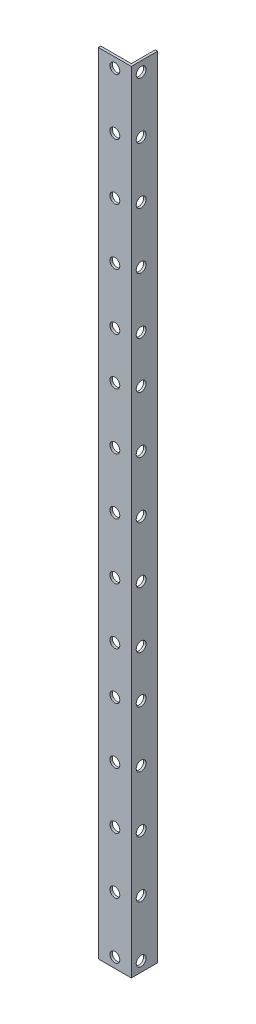
from build123d import *

# Parameters (mm, degrees)
BOSS_EXTRUDE1_DEPTH       = 360
CUT_EXTRUDE1_REACH        = 3.1
SKETCH2_R                 = 2.25
SKETCH3_R                 = 2.25
CUT_EXTRUDE2_DEPTH        = 1.1
LPATTERN1_COUNT           = 5
LPATTERN1_PITCH           = 25.65625
LPATTERN2_COUNT           = 3
LPATTERN2_PITCH           = 124.1875
LPATTERN2_COPY_1_SKETCH_R = 2.25
LPATTERN2_COPY_1_DEPTH    = 1.1
LPATTERN2_COPY_2_SKETCH_R = 2.25
LPATTERN2_COPY_2_DEPTH    = 1.1
LPATTERN2_COPY_3_SKETCH_R = 2.25
LPATTERN2_COPY_3_DEPTH    = 1.1
LPATTERN2_COPY_4_SKETCH_R = 2.25
LPATTERN2_COPY_4_DEPTH    = 1.1
LPATTERN2_COPY_5_SKETCH_R = 2.25
LPATTERN2_COPY_5_DEPTH    = 1.1
LPATTERN2_COPY_6_SKETCH_R = 2.25
LPATTERN2_COPY_6_DEPTH    = 1.1
LPATTERN2_COPY_7_SKETCH_R = 2.25
LPATTERN2_COPY_7_DEPTH    = 1.1
LPATTERN2_COPY_8_SKETCH_R = 2.25
LPATTERN2_COPY_8_DEPTH    = 1.1


with BuildPart() as part:
    # Sketch1 → Boss-Extrude1 (new body)
    with BuildSketch(Plane(origin=(0, 0, 0), x_dir=(1, 0, 0), z_dir=(0, 1, 0))):
        Polygon((0, 0), (15, 0), (15, 12), (13.9, 12), (13.9, 1.1), (0, 1.1), align=None)
    extrude(amount=BOSS_EXTRUDE1_DEPTH)

    # Sketch2 → Cut-Extrude1 (cut, up to next)
    with BuildSketch(Plane.ZY.offset(-13.9), mode=Mode.PRIVATE) as cut_extrude1_sk1:
        with Locations((-4.5, 329.8125)):
            Circle(SKETCH2_R)
    cut_extrude1_tool1 = extrude(cut_extrude1_sk1.sketch, amount=-CUT_EXTRUDE1_REACH, mode=Mode.PRIVATE) & part.part
    add(cut_extrude1_tool1.solids().sort_by_distance((13.9, 329.8125, -4.5))[0], mode=Mode.SUBTRACT)
    # Sketch2 → Cut-Extrude1 (cut, up to next)
    with BuildSketch(Plane.ZY.offset(-13.9), mode=Mode.PRIVATE) as cut_extrude1_sk2:
        with Locations((-4.5, 304.125)):
            Circle(SKETCH2_R)
    cut_extrude1_tool2 = extrude(cut_extrude1_sk2.sketch, amount=-CUT_EXTRUDE1_REACH, mode=Mode.PRIVATE) & part.part
    add(cut_extrude1_tool2.solids().sort_by_distance((13.9, 304.125, -4.5))[0], mode=Mode.SUBTRACT)
    # Sketch2 → Cut-Extrude1 (cut, up to next)
    with BuildSketch(Plane.ZY.offset(-13.9), mode=Mode.PRIVATE) as cut_extrude1_sk3:
        with Locations((-4.5, 278.4375)):
            Circle(SKETCH2_R)
    cut_extrude1_tool3 = extrude(cut_extrude1_sk3.sketch, amount=-CUT_EXTRUDE1_REACH, mode=Mode.PRIVATE) & part.part
    add(cut_extrude1_tool3.solids().sort_by_distance((13.9, 278.4375, -4.5))[0], mode=Mode.SUBTRACT)
    # Sketch2 → Cut-Extrude1 (cut, up to next)
    with BuildSketch(Plane.ZY.offset(-13.9), mode=Mode.PRIVATE) as cut_extrude1_sk4:
        with Locations((-4.5, 252.75)):
            Circle(SKETCH2_R)
    cut_extrude1_tool4 = extrude(cut_extrude1_sk4.sketch, amount=-CUT_EXTRUDE1_REACH, mode=Mode.PRIVATE) & part.part
    add(cut_extrude1_tool4.solids().sort_by_distance((13.9, 252.75, -4.5))[0], mode=Mode.SUBTRACT)
    # Sketch2 → Cut-Extrude1 (cut, up to next)
    with BuildSketch(Plane.ZY.offset(-13.9), mode=Mode.PRIVATE) as cut_extrude1_sk5:
        with Locations((-4.5, 231.375)):
            Circle(SKETCH2_R)
    cut_extrude1_tool5 = extrude(cut_extrude1_sk5.sketch, amount=-CUT_EXTRUDE1_REACH, mode=Mode.PRIVATE) & part.part
    add(cut_extrude1_tool5.solids().sort_by_distance((13.9, 231.375, -4.5))[0], mode=Mode.SUBTRACT)
    # Sketch2 → Cut-Extrude1 (cut, up to next)
    with BuildSketch(Plane.ZY.offset(-13.9), mode=Mode.PRIVATE) as cut_extrude1_sk6:
        with Locations((-4.5, 205.6875)):
            Circle(SKETCH2_R)
    cut_extrude1_tool6 = extrude(cut_extrude1_sk6.sketch, amount=-CUT_EXTRUDE1_REACH, mode=Mode.PRIVATE) & part.part
    add(cut_extrude1_tool6.solids().sort_by_distance((13.9, 205.6875, -4.5))[0], mode=Mode.SUBTRACT)
    # Sketch2 → Cut-Extrude1 (cut, up to next)
    with BuildSketch(Plane.ZY.offset(-13.9), mode=Mode.PRIVATE) as cut_extrude1_sk7:
        with Locations((-4.5, 180)):
            Circle(SKETCH2_R)
    cut_extrude1_tool7 = extrude(cut_extrude1_sk7.sketch, amount=-CUT_EXTRUDE1_REACH, mode=Mode.PRIVATE) & part.part
    add(cut_extrude1_tool7.solids().sort_by_distance((13.9, 180, -4.5))[0], mode=Mode.SUBTRACT)
    # Sketch2 → Cut-Extrude1 (cut, up to next)
    with BuildSketch(Plane.ZY.offset(-13.9), mode=Mode.PRIVATE) as cut_extrude1_sk8:
        with Locations((-4.5, 154.3125)):
            Circle(SKETCH2_R)
    cut_extrude1_tool8 = extrude(cut_extrude1_sk8.sketch, amount=-CUT_EXTRUDE1_REACH, mode=Mode.PRIVATE) & part.part
    add(cut_extrude1_tool8.solids().sort_by_distance((13.9, 154.3125, -4.5))[0], mode=Mode.SUBTRACT)
    # Sketch2 → Cut-Extrude1 (cut, up to next)
    with BuildSketch(Plane.ZY.offset(-13.9), mode=Mode.PRIVATE) as cut_extrude1_sk9:
        with Locations((-4.5, 128.625)):
            Circle(SKETCH2_R)
    cut_extrude1_tool9 = extrude(cut_extrude1_sk9.sketch, amount=-CUT_EXTRUDE1_REACH, mode=Mode.PRIVATE) & part.part
    add(cut_extrude1_tool9.solids().sort_by_distance((13.9, 128.625, -4.5))[0], mode=Mode.SUBTRACT)
    # Sketch2 → Cut-Extrude1 (cut, up to next)
    with BuildSketch(Plane.ZY.offset(-13.9), mode=Mode.PRIVATE) as cut_extrude1_sk10:
        with Locations((-4.5, 107.25)):
            Circle(SKETCH2_R)
    cut_extrude1_tool10 = extrude(cut_extrude1_sk10.sketch, amount=-CUT_EXTRUDE1_REACH, mode=Mode.PRIVATE) & part.part
    add(cut_extrude1_tool10.solids().sort_by_distance((13.9, 107.25, -4.5))[0], mode=Mode.SUBTRACT)
    # Sketch2 → Cut-Extrude1 (cut, up to next)
    with BuildSketch(Plane.ZY.offset(-13.9), mode=Mode.PRIVATE) as cut_extrude1_sk11:
        with Locations((-4.5, 81.5625)):
            Circle(SKETCH2_R)
    cut_extrude1_tool11 = extrude(cut_extrude1_sk11.sketch, amount=-CUT_EXTRUDE1_REACH, mode=Mode.PRIVATE) & part.part
    add(cut_extrude1_tool11.solids().sort_by_distance((13.9, 81.5625, -4.5))[0], mode=Mode.SUBTRACT)
    # Sketch2 → Cut-Extrude1 (cut, up to next)
    with BuildSketch(Plane.ZY.offset(-13.9), mode=Mode.PRIVATE) as cut_extrude1_sk12:
        with Locations((-4.5, 55.875)):
            Circle(SKETCH2_R)
    cut_extrude1_tool12 = extrude(cut_extrude1_sk12.sketch, amount=-CUT_EXTRUDE1_REACH, mode=Mode.PRIVATE) & part.part
    add(cut_extrude1_tool12.solids().sort_by_distance((13.9, 55.875, -4.5))[0], mode=Mode.SUBTRACT)
    # Sketch2 → Cut-Extrude1 (cut, up to next)
    with BuildSketch(Plane.ZY.offset(-13.9), mode=Mode.PRIVATE) as cut_extrude1_sk13:
        with Locations((-4.5, 30.1875)):
            Circle(SKETCH2_R)
    cut_extrude1_tool13 = extrude(cut_extrude1_sk13.sketch, amount=-CUT_EXTRUDE1_REACH, mode=Mode.PRIVATE) & part.part
    add(cut_extrude1_tool13.solids().sort_by_distance((13.9, 30.1875, -4.5))[0], mode=Mode.SUBTRACT)
    # Sketch2 → Cut-Extrude1 (cut, up to next)
    with BuildSketch(Plane.ZY.offset(-13.9), mode=Mode.PRIVATE) as cut_extrude1_sk14:
        with Locations((-4.5, 4.5)):
            Circle(SKETCH2_R)
    cut_extrude1_tool14 = extrude(cut_extrude1_sk14.sketch, amount=-CUT_EXTRUDE1_REACH, mode=Mode.PRIVATE) & part.part
    add(cut_extrude1_tool14.solids().sort_by_distance((13.9, 4.5, -4.5))[0], mode=Mode.SUBTRACT)
    # Sketch2 → Cut-Extrude1 (cut, up to next)
    with BuildSketch(Plane.ZY.offset(-13.9), mode=Mode.PRIVATE) as cut_extrude1_sk15:
        with Locations((-4.5, 355.5)):
            Circle(SKETCH2_R)
    cut_extrude1_tool15 = extrude(cut_extrude1_sk15.sketch, amount=-CUT_EXTRUDE1_REACH, mode=Mode.PRIVATE) & part.part
    add(cut_extrude1_tool15.solids().sort_by_distance((13.9, 355.5, -4.5))[0], mode=Mode.SUBTRACT)

    # Sketch3 → Cut-Extrude2 (cut)
    with BuildSketch(Plane.XY):
        with Locations((7.5, 355.5)):
            Circle(SKETCH3_R)
    cut_extrude2 = extrude(amount=-CUT_EXTRUDE2_DEPTH, mode=Mode.SUBTRACT)

    # LPattern1: Cut-Extrude2 ×5
    with Locations(*[(0, -i * LPATTERN1_PITCH, 0) for i in range(1, LPATTERN1_COUNT)]):
        add(cut_extrude2, mode=Mode.SUBTRACT)

    # LPattern2: Cut-Extrude2 ×3
    with Locations(*[(0, -i * LPATTERN2_PITCH, 0) for i in range(1, LPATTERN2_COUNT)]):
        add(cut_extrude2, mode=Mode.SUBTRACT)

    # LPattern2 copy 1 sketch → LPattern2 copy 1 (cut)
    with BuildSketch(Plane(origin=(0, -149.84375, 0), x_dir=(1, 0, 0), z_dir=(0, 0, 1))):
        with Locations((7.5, 355.5)):
            Circle(LPATTERN2_COPY_1_SKETCH_R)
    extrude(amount=-LPATTERN2_COPY_1_DEPTH, mode=Mode.SUBTRACT)

    # LPattern2 copy 2 sketch → LPattern2 copy 2 (cut)
    with BuildSketch(Plane(origin=(0, -274.03125, 0), x_dir=(1, 0, 0), z_dir=(0, 0, 1))):
        with Locations((7.5, 355.5)):
            Circle(LPATTERN2_COPY_2_SKETCH_R)
    extrude(amount=-LPATTERN2_COPY_2_DEPTH, mode=Mode.SUBTRACT)

    # LPattern2 copy 3 sketch → LPattern2 copy 3 (cut)
    with BuildSketch(Plane(origin=(0, -175.5, 0), x_dir=(1, 0, 0), z_dir=(0, 0, 1))):
        with Locations((7.5, 355.5)):
            Circle(LPATTERN2_COPY_3_SKETCH_R)
    extrude(amount=-LPATTERN2_COPY_3_DEPTH, mode=Mode.SUBTRACT)

    # LPattern2 copy 4 sketch → LPattern2 copy 4 (cut)
    with BuildSketch(Plane(origin=(0, -299.6875, 0), x_dir=(1, 0, 0), z_dir=(0, 0, 1))):
        with Locations((7.5, 355.5)):
            Circle(LPATTERN2_COPY_4_SKETCH_R)
    extrude(amount=-LPATTERN2_COPY_4_DEPTH, mode=Mode.SUBTRACT)

    # LPattern2 copy 5 sketch → LPattern2 copy 5 (cut)
    with BuildSketch(Plane(origin=(0, -201.15625, 0), x_dir=(1, 0, 0), z_dir=(0, 0, 1))):
        with Locations((7.5, 355.5)):
            Circle(LPATTERN2_COPY_5_SKETCH_R)
    extrude(amount=-LPATTERN2_COPY_5_DEPTH, mode=Mode.SUBTRACT)

    # LPattern2 copy 6 sketch → LPattern2 copy 6 (cut)
    with BuildSketch(Plane(origin=(0, -325.34375, 0), x_dir=(1, 0, 0), z_dir=(0, 0, 1))):
        with Locations((7.5, 355.5)):
            Circle(LPATTERN2_COPY_6_SKETCH_R)
    extrude(amount=-LPATTERN2_COPY_6_DEPTH, mode=Mode.SUBTRACT)

    # LPattern2 copy 7 sketch → LPattern2 copy 7 (cut)
    with BuildSketch(Plane(origin=(0, -226.8125, 0), x_dir=(1, 0, 0), z_dir=(0, 0, 1))):
        with Locations((7.5, 355.5)):
            Circle(LPATTERN2_COPY_7_SKETCH_R)
    extrude(amount=-LPATTERN2_COPY_7_DEPTH, mode=Mode.SUBTRACT)

    # LPattern2 copy 8 sketch → LPattern2 copy 8 (cut)
    with BuildSketch(Plane(origin=(0, -351, 0), x_dir=(1, 0, 0), z_dir=(0, 0, 1))):
        with Locations((7.5, 355.5)):
            Circle(LPATTERN2_COPY_8_SKETCH_R)
    extrude(amount=-LPATTERN2_COPY_8_DEPTH, mode=Mode.SUBTRACT)


solid = part.part
